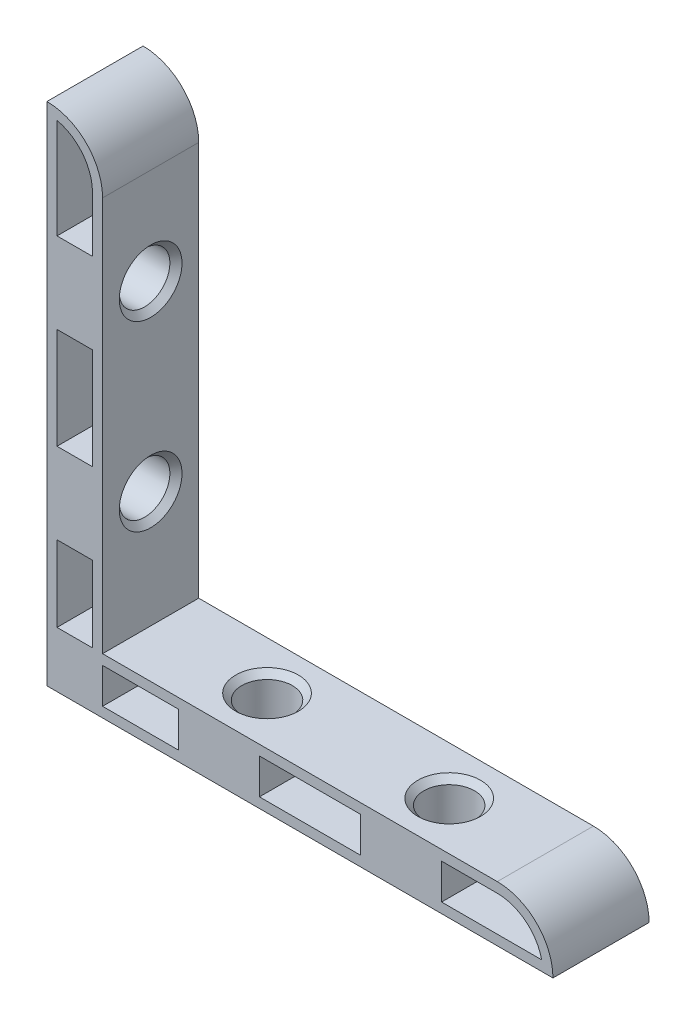
from build123d import *

# Parameters (mm, degrees)
EXTRUDE_1_DEPTH            = 4.75
EXTRUDE_START              = -4.75
SKETCH_2_W                 = 5.5
SKETCH_2_H                 = 5.5
SKETCH_2_H_2               = 8
SKETCH_2_W_2               = 8
EXTRUDE_2_DEPTH            = 9.5
EXTRUDE_3_DEPTH            = 1
HOLE_WIZARD_M61_AT_2_COUNT = 2
HOLE_WIZARD_M61_AT_2_PITCH = 18


with BuildPart() as part:
    # Эскиз1 → Бобышка-Вытянуть1 (new body, symmetric)
    with BuildSketch(Plane.XY):
        with BuildLine():
            Line((0, 50), (0, 0))
            Line((0, 0), (50, 0))
            ThreePointArc((50, 0), (48.389087297, 3.889087297), (44.5, 5.5))
            Line((44.5, 5.5), (5.5, 5.5))
            Line((5.5, 5.5), (5.5, 44.5))
            ThreePointArc((5.5, 44.5), (3.889087297, 48.389087297), (0, 50))
        make_face()
        with BuildLine():
            Line((1, 48.887482194), (1, 1))
            Line((1, 1), (48.887482194, 1))
            ThreePointArc((48.887482194, 1), (47.30624304, 3.51781182), (44.5, 4.5))
            Line((44.5, 4.5), (4.5, 4.5))
            Line((4.5, 4.5), (4.5, 44.5))
            ThreePointArc((4.5, 44.5), (3.51781182, 47.30624304), (1, 48.887482194))
        make_face(mode=Mode.SUBTRACT)
    extrude(amount=EXTRUDE_1_DEPTH, both=True)

    # Эскиз2 → Бобышка-Вытянуть2 (add)
    with BuildSketch(Plane.XY.offset(EXTRUDE_START)):
        with Locations((2.75, 2.75)):
            Rectangle(SKETCH_2_W, SKETCH_2_H)
        with Locations((2.75, 35)):
            Rectangle(SKETCH_2_W, SKETCH_2_H_2)
        with Locations((2.75, 17)):
            Rectangle(SKETCH_2_W, SKETCH_2_H_2)
        with Locations((17, 2.75)):
            Rectangle(SKETCH_2_W_2, SKETCH_2_H)
        with Locations((35, 2.75)):
            Rectangle(SKETCH_2_W_2, SKETCH_2_H)
    extrude(amount=EXTRUDE_2_DEPTH)

    # Эскиз3 → Бобышка-Вытянуть3 (add, symmetric)
    with BuildSketch(Plane.XY):
        with BuildLine():
            Line((0, 0), (50, 0))
            ThreePointArc((50, 0), (48.389087297, 3.889087297), (44.5, 5.5))
            Line((44.5, 5.5), (5.5, 5.5))
            Line((5.5, 5.5), (5.5, 44.5))
            ThreePointArc((5.5, 44.5), (3.889087297, 48.389087297), (0, 50))
            Line((0, 50), (0, 0))
        make_face()
    extrude(amount=EXTRUDE_3_DEPTH, both=True)

    # Эскиз5 → Отверстие обработанное метчиком M61 (revolve, cut)
    with BuildSketch(Plane.ZX.offset(35)):
        Polygon((0, 0), (0, 5.5), (3.1, 5.5), (2.5, 4.9), (2.5, 0.6), (3.1, 0), align=None)
    hole_wizard_m61 = revolve(axis=Axis((-6.35, 35, 0), (1, 0, 0)), mode=Mode.SUBTRACT)

    # Отверстие обработанное метчиком M61 at 2: Отверстие обработанное метчиком M61 ×2
    with Locations(*[(0, -i * HOLE_WIZARD_M61_AT_2_PITCH, 0) for i in range(1, HOLE_WIZARD_M61_AT_2_COUNT)]):
        add(hole_wizard_m61, mode=Mode.SUBTRACT)

    # Зеркальное отражение1: Отверстие обработанное метчиком M61 across plane
    add(hole_wizard_m61.mirror(Plane(origin=(0, 0, 0), x_dir=(0, 0, 1), z_dir=(-0.707106781, 0.707106781, 0))), mode=Mode.SUBTRACT)

    # Зеркальное отражение1 copy 1 sketch → Зеркальное отражение1 copy 1 (revolve, cut)
    with BuildSketch(Plane(origin=(17, 0, 0), x_dir=(0, 0, 1), z_dir=(1, 0, 0))):
        Polygon((0, 0), (0, -5.5), (3.1, -5.5), (2.5, -4.9), (2.5, -0.6), (3.1, 0), align=None)
    revolve(axis=Axis((17, -6.35, 0), (0, -1, 0)), mode=Mode.SUBTRACT)


solid = part.part
